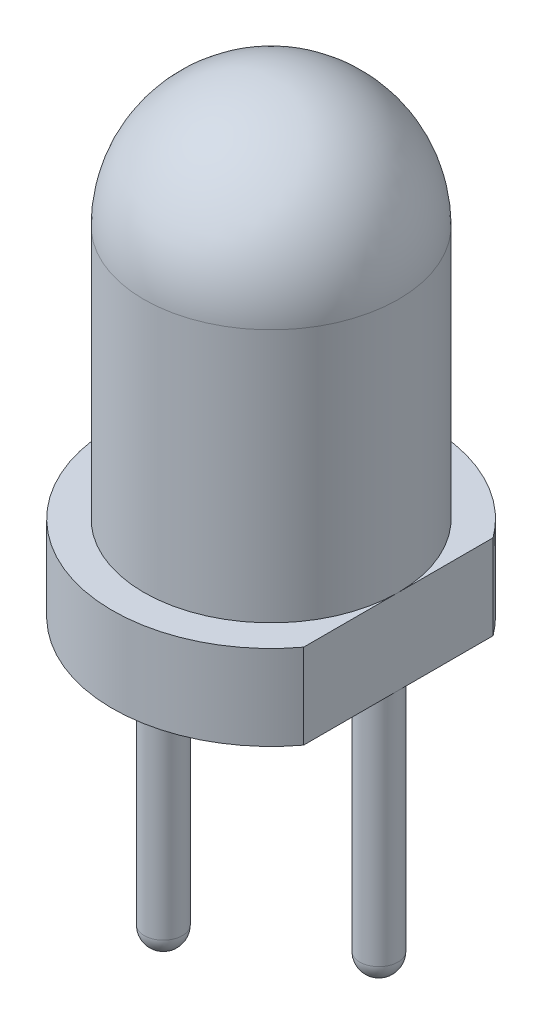
from build123d import *

# Parameters (mm, degrees)
CORTAR_EXTRUIR1_REACH   = 7.49
CROQUIS1_R              = 0.225
SALIENTE_EXTRUIR1_DEPTH = 4
CROQUIS2_R              = 0.225
CORTAR_EXTRUIR2_DEPTH   = 1
REDONDEO1_R             = 0.225


with BuildPart() as part:
    # Sketch2 → Revolve1 (revolve)
    with BuildSketch(Plane.XY):
        with BuildLine():
            Line((0, 0), (-1.87, 0))
            Line((-1.87, 0), (-1.87, 1))
            Line((-1.87, 1), (-1.5, 1))
            Line((-1.5, 1), (-1.5, 3.99))
            ThreePointArc((-1.5, 3.99), (-1.060660172, 5.050660172), (0, 5.49))
            Line((0, 5.49), (0, 0))
        make_face()
    revolve(axis=Axis((0, 0, 0), (0, 1, 0)))

    # Sketch3 → Cortar-Extruir1 (cut, up to next)
    with BuildSketch(Plane.XZ, mode=Mode.PRIVATE) as cortar_extruir1_sk1:
        Polygon((1.5, 20.122635641), (1.5, 1.116646766), (1.5, -1.116646766), (1.5, -20.122635641), (39.51197775, -20.122635641), (39.51197775, 20.122635641), align=None)
    cortar_extruir1_tool1 = extrude(cortar_extruir1_sk1.sketch, amount=-CORTAR_EXTRUIR1_REACH, mode=Mode.PRIVATE) & part.part
    add(cortar_extruir1_tool1.solids().sort_by_distance((20.505989, 0, 0))[0], mode=Mode.SUBTRACT)

    # Croquis1 → Saliente-Extruir1 (add)
    with BuildSketch(Plane.XZ):
        with Locations((1.27, 0)):
            Circle(CROQUIS1_R)
        with Locations((-1.27, 0)):
            Circle(CROQUIS1_R)
    extrude(amount=SALIENTE_EXTRUIR1_DEPTH)

    # Croquis2 → Cortar-Extruir2 (cut)
    with BuildSketch(Plane.XZ.offset(4)):
        with Locations((1.27, 0)):
            Circle(CROQUIS2_R)
    extrude(amount=-CORTAR_EXTRUIR2_DEPTH, mode=Mode.SUBTRACT)

    # Redondeo1
    redondeo1_edges = [part.edges().sort_by_distance(p)[0] for p in [
        (-1.495, -4, 0),
        (1.045, -3, 0),
    ]]
    fillet(redondeo1_edges, radius=REDONDEO1_R)


solid = part.part
